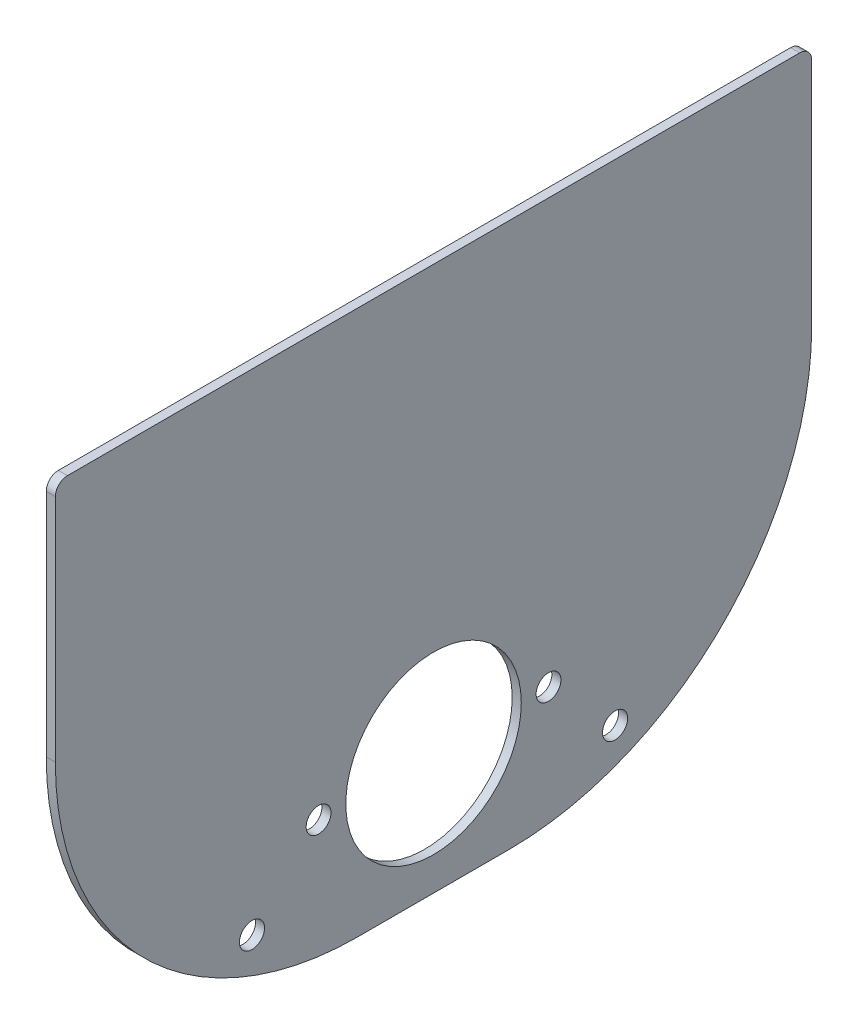
from build123d import *

# Parameters (mm, degrees)
SKETCH_1_R      = 29
SKETCH_1_R_2    = 4.1
SKETCH_1_R_3    = 4.15
EXTRUDE_1_DEPTH = 3


with BuildPart() as part:
    # Эскиз1 → Бобышка-Вытянуть1 (new body)
    with BuildSketch(Plane(origin=(0, 0, 0), x_dir=(0, 0, -1), z_dir=(1, 0, 0))):
        with BuildLine():
            Line((-121, 140), (121, 140))
            ThreePointArc((121, 140), (123.828427125, 138.828427125), (125, 136))
            Line((125, 136), (125, 60))
            ThreePointArc((125, 60), (95.710678119, -10.710678119), (25, -40))
            Line((25, -40), (-25, -40))
            ThreePointArc((-25, -40), (-95.710678119, -10.710678119), (-125, 60))
            Line((-125, 60), (-125, 136))
            ThreePointArc((-125, 136), (-123.828427125, 138.828427125), (-121, 140))
        make_face()
        Circle(SKETCH_1_R, mode=Mode.SUBTRACT)
        with Locations((38, 0)):
            Circle(SKETCH_1_R_2, mode=Mode.SUBTRACT)
        with Locations((-38, 0)):
            Circle(SKETCH_1_R_2, mode=Mode.SUBTRACT)
        with Locations((-60, -22)):
            Circle(SKETCH_1_R_3, mode=Mode.SUBTRACT)
        with Locations((60, -22)):
            Circle(SKETCH_1_R_3, mode=Mode.SUBTRACT)
    extrude(amount=EXTRUDE_1_DEPTH)


solid = part.part
